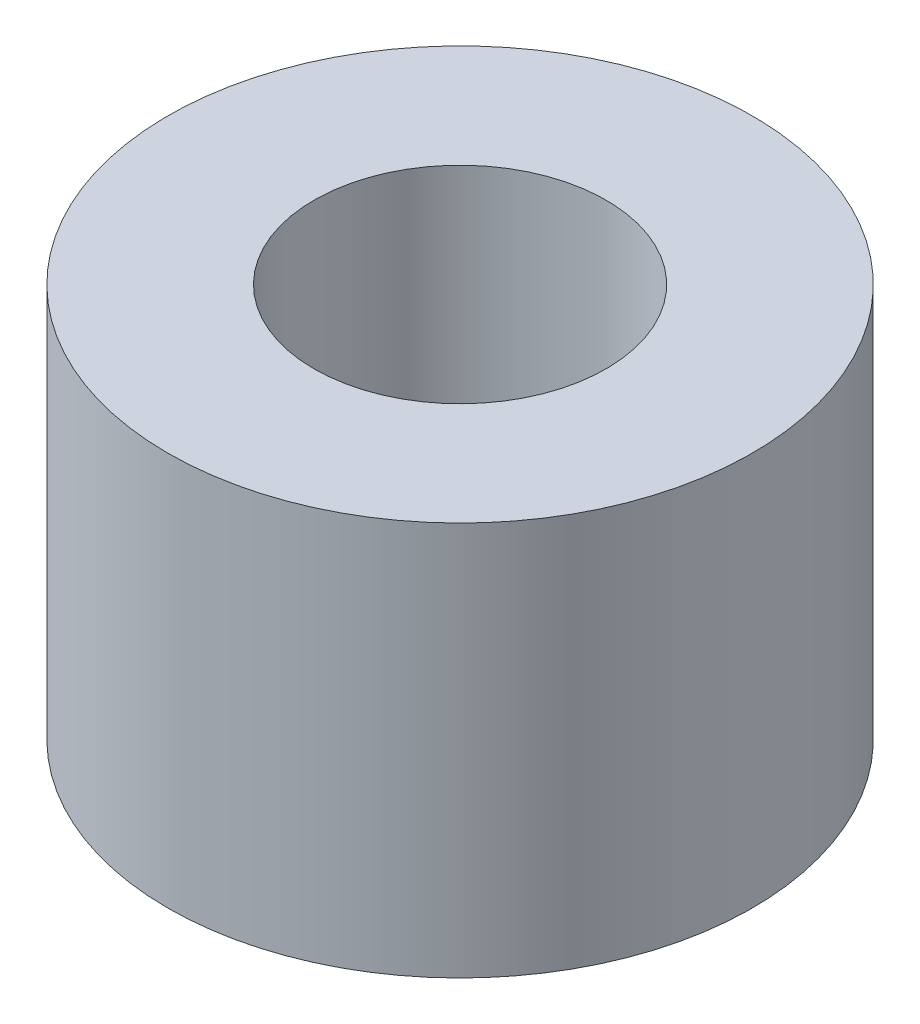
from build123d import *

# Parameters (mm, degrees)
SKETCH1_R           = 6.35
SKETCH1_R_2         = 3.175
BOSS_EXTRUDE1_DEPTH = 8.56234


with BuildPart() as part:
    # Sketch1 → Boss-Extrude1 (new body)
    with BuildSketch(Plane(origin=(0, 0, 0), x_dir=(1, 0, 0), z_dir=(0, 1, 0))):
        Circle(SKETCH1_R)
        Circle(SKETCH1_R_2, mode=Mode.SUBTRACT)
    extrude(amount=BOSS_EXTRUDE1_DEPTH)


solid = part.part
